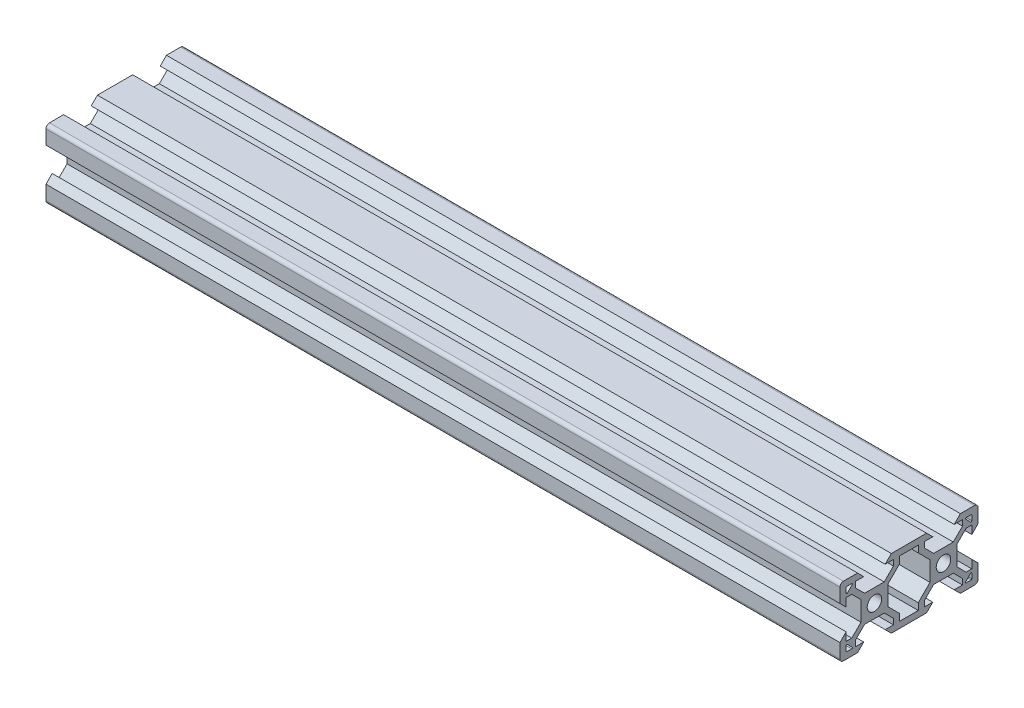
from build123d import *

# Parameters (mm, degrees)
SKETCH5_R           = 2.1
BOSS_EXTRUDE1_DEPTH = 115


with BuildPart() as part:
    # Sketch5 → Boss-Extrude1 (new body, symmetric)
    with BuildSketch(Plane(origin=(0, 0, 0), x_dir=(0, 0, -1), z_dir=(1, 0, 0))):
        with BuildLine():
            Line((-19.998019485, 4.9), (-18.198019485, 3.1))
            Line((-18.198019485, 3.1), (-18.198019485, 5.499339828))
            Line((-18.198019485, 5.499339828), (-16.558019485, 5.499339828))
            Line((-16.558019485, 5.499339828), (-13.9, 2.841320344))
            Line((-13.9, 2.841320344), (-13.9, -2.838679656))
            Line((-13.9, -2.838679656), (-16.558019485, -5.496699141))
            Line((-16.558019485, -5.496699141), (-18.198019485, -5.496699141))
            Line((-18.198019485, -5.496699141), (-18.198019485, -3.1))
            Line((-18.198019485, -3.1), (-19.998019485, -4.9))
            Line((-19.998019485, -4.9), (-19.998019485, -9))
            ThreePointArc((-19.998019485, -9), (-19.705126266, -9.707106781), (-18.998019485, -10))
            Line((-18.998019485, -10), (-14.9, -10))
            Line((-14.9, -10), (-13.1, -8.2))
            Line((-13.1, -8.2), (-15.5, -8.2))
            Line((-15.5, -8.2), (-15.5, -6.56))
            Line((-15.5, -6.56), (-12.84, -3.9))
            Line((-12.84, -3.9), (-7.16, -3.9))
            Line((-7.16, -3.9), (-4.5, -6.56))
            Line((-4.5, -6.56), (-4.5, -8.2))
            Line((-4.5, -8.2), (-6.9, -8.2))
            Line((-6.9, -8.2), (-5.1, -10))
            Line((-5.1, -10), (5.1, -10))
            Line((5.1, -10), (6.9, -8.2))
            Line((6.9, -8.2), (4.496038969, -8.2))
            Line((4.496038969, -8.2), (4.496038969, -6.56))
            Line((4.496038969, -6.56), (7.156038969, -3.9))
            Line((7.156038969, -3.9), (12.836038969, -3.9))
            Line((12.836038969, -3.9), (15.496038969, -6.56))
            Line((15.496038969, -6.56), (15.496038969, -8.2))
            Line((15.496038969, -8.2), (13.1, -8.2))
            Line((13.1, -8.2), (14.9, -10))
            Line((14.9, -10), (19.001980515, -10))
            ThreePointArc((19.001980515, -10), (19.709087297, -9.707106781), (20.001980515, -9))
            Line((20.001980515, -9), (20.001980515, -4.9))
            Line((20.001980515, -4.9), (18.201980515, -3.1))
            Line((18.201980515, -3.1), (18.201980515, -5.504621202))
            Line((18.201980515, -5.504621202), (16.561980515, -5.504621202))
            Line((16.561980515, -5.504621202), (13.9, -2.842640687))
            Line((13.9, -2.842640687), (13.9, 2.837359313))
            Line((13.9, 2.837359313), (16.561980515, 5.499339828))
            Line((16.561980515, 5.499339828), (18.201980515, 5.499339828))
            Line((18.201980515, 5.499339828), (18.201980515, 3.1))
            Line((18.201980515, 3.1), (20.001980515, 4.9))
            Line((20.001980515, 4.9), (20.001980515, 9))
            ThreePointArc((20.001980515, 9), (19.709087297, 9.707106781), (19.001980515, 10))
            Line((19.001980515, 10), (14.9, 10))
            Line((14.9, 10), (13.1, 8.2))
            Line((13.1, 8.2), (15.501320344, 8.2))
            Line((15.501320344, 8.2), (15.501320344, 6.56))
            Line((15.501320344, 6.56), (12.841320344, 3.9))
            Line((12.841320344, 3.9), (7.161320344, 3.9))
            Line((7.161320344, 3.9), (4.501320344, 6.56))
            Line((4.501320344, 6.56), (4.501320344, 8.2))
            Line((4.501320344, 8.2), (6.9, 8.2))
            Line((6.9, 8.2), (5.1, 10))
            Line((5.1, 10), (-5.1, 10))
            Line((-5.1, 10), (-6.9, 8.2))
            Line((-6.9, 8.2), (-4.501320344, 8.2))
            Line((-4.501320344, 8.2), (-4.501320344, 6.56))
            Line((-4.501320344, 6.56), (-7.161320344, 3.9))
            Line((-7.161320344, 3.9), (-12.841320344, 3.9))
            Line((-12.841320344, 3.9), (-15.501320344, 6.56))
            Line((-15.501320344, 6.56), (-15.501320344, 8.2))
            Line((-15.501320344, 8.2), (-13.1, 8.2))
            Line((-13.1, 8.2), (-14.9, 10))
            Line((-14.9, 10), (-18.998019485, 10))
            ThreePointArc((-18.998019485, 10), (-19.705126266, 9.707106781), (-19.998019485, 9))
            Line((-19.998019485, 9), (-19.998019485, 4.9))
        make_face()
        with Locations((-10, 0)):
            Circle(SKETCH5_R, mode=Mode.SUBTRACT)
        with Locations((10, 0)):
            Circle(SKETCH5_R, mode=Mode.SUBTRACT)
        Polygon((6.1, -2.84), (6.1, 2.84), (2.7, 6.24), (2.7, 8.2), (-2.7, 8.2), (-2.7, 6.24), (-6.1, 2.84), (-6.1, -2.84), (-2.7, -6.24), (-2.7, -8.2), (2.7, -8.2), (2.7, -6.24), align=None, mode=Mode.SUBTRACT)
        with BuildLine():
            Line((16.571320344, 8.2), (18.001980515, 8.2))
            ThreePointArc((18.001980515, 8.2), (18.143401872, 8.141421356), (18.201980515, 8))
            Line((18.201980515, 8), (18.201980515, 6.569339828))
            ThreePointArc((18.201980515, 6.569339828), (18.078517202, 6.384563922), (17.860559159, 6.427918472))
            Line((17.860559159, 6.427918472), (16.429898987, 7.858578644))
            ThreePointArc((16.429898987, 7.858578644), (16.386544437, 8.076536686), (16.571320344, 8.2))
        make_face(mode=Mode.SUBTRACT)
        with BuildLine():
            Line((16.571320344, -8.2), (18.001980515, -8.2))
            ThreePointArc((18.001980515, -8.2), (18.143401872, -8.141421356), (18.201980515, -8))
            Line((18.201980515, -8), (18.201980515, -6.569339828))
            ThreePointArc((18.201980515, -6.569339828), (18.078517202, -6.384563922), (17.860559159, -6.427918472))
            Line((17.860559159, -6.427918472), (16.429898987, -7.858578644))
            ThreePointArc((16.429898987, -7.858578644), (16.386544437, -8.076536686), (16.571320344, -8.2))
        make_face(mode=Mode.SUBTRACT)
        with BuildLine():
            Line((-17.860559159, 6.427918472), (-16.429898987, 7.858578644))
            ThreePointArc((-16.429898987, 7.858578644), (-16.386544437, 8.076536686), (-16.571320344, 8.2))
            Line((-16.571320344, 8.2), (-18.001980515, 8.2))
            ThreePointArc((-18.001980515, 8.2), (-18.143401872, 8.141421356), (-18.201980515, 8))
            Line((-18.201980515, 8), (-18.201980515, 6.569339828))
            ThreePointArc((-18.201980515, 6.569339828), (-18.078517202, 6.384563922), (-17.860559159, 6.427918472))
        make_face(mode=Mode.SUBTRACT)
        with BuildLine():
            Line((-16.571320344, -8.2), (-18.001980515, -8.2))
            ThreePointArc((-18.001980515, -8.2), (-18.143401872, -8.141421356), (-18.201980515, -8))
            Line((-18.201980515, -8), (-18.201980515, -6.569339828))
            ThreePointArc((-18.201980515, -6.569339828), (-18.078517202, -6.384563922), (-17.860559159, -6.427918472))
            Line((-17.860559159, -6.427918472), (-16.429898987, -7.858578644))
            ThreePointArc((-16.429898987, -7.858578644), (-16.386544437, -8.076536686), (-16.571320344, -8.2))
        make_face(mode=Mode.SUBTRACT)
    extrude(amount=BOSS_EXTRUDE1_DEPTH, both=True)


solid = part.part
